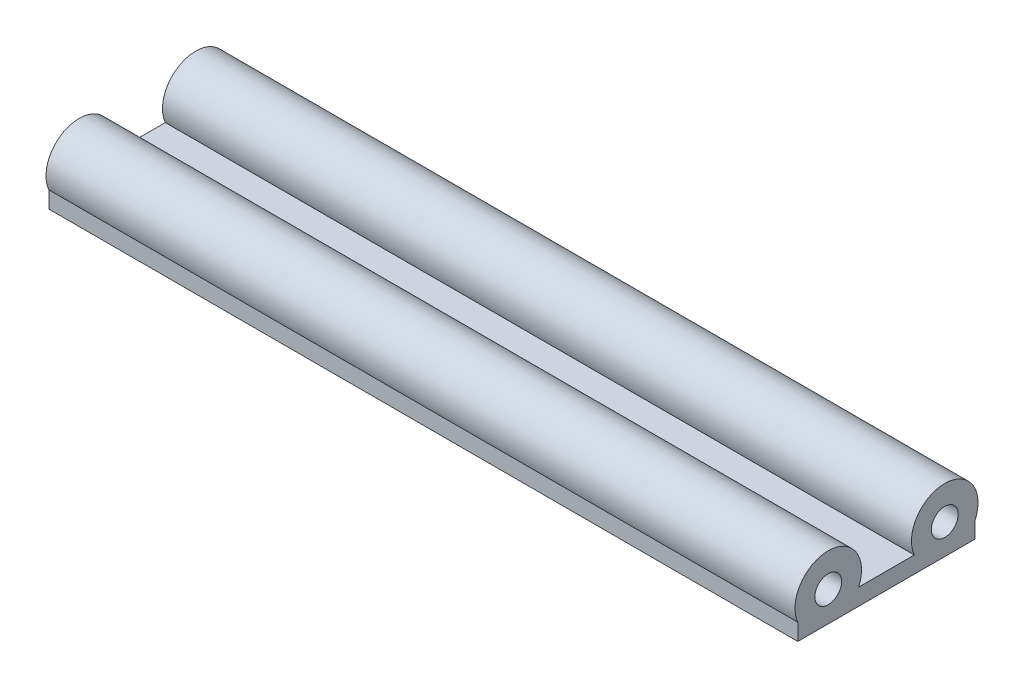
from build123d import *

# Parameters (mm, degrees)
SKETCH1_R           = 3.225
BOSS_EXTRUDE1_DEPTH = 180


with BuildPart() as part:
    # Sketch1 → Boss-Extrude1 (new body)
    with BuildSketch(Plane(origin=(0, 0, 0), x_dir=(0, 0, -1), z_dir=(1, 0, 0))):
        with BuildLine():
            Line((-20.678840597, -3.225), (-7.321159403, -3.225))
            ThreePointArc((-7.321159403, -3.225), (0, 8), (7.321159403, -3.225))
            Line((7.321159403, -3.225), (7.321159403, -7.225))
            Line((7.321159403, -7.225), (-35.321159403, -7.225))
            Line((-35.321159403, -7.225), (-35.321159403, -3.225))
            ThreePointArc((-35.321159403, -3.225), (-28, 8), (-20.678840597, -3.225))
        make_face()
        Circle(SKETCH1_R, mode=Mode.SUBTRACT)
        with Locations((-28, 0)):
            Circle(SKETCH1_R, mode=Mode.SUBTRACT)
    extrude(amount=BOSS_EXTRUDE1_DEPTH)


solid = part.part
